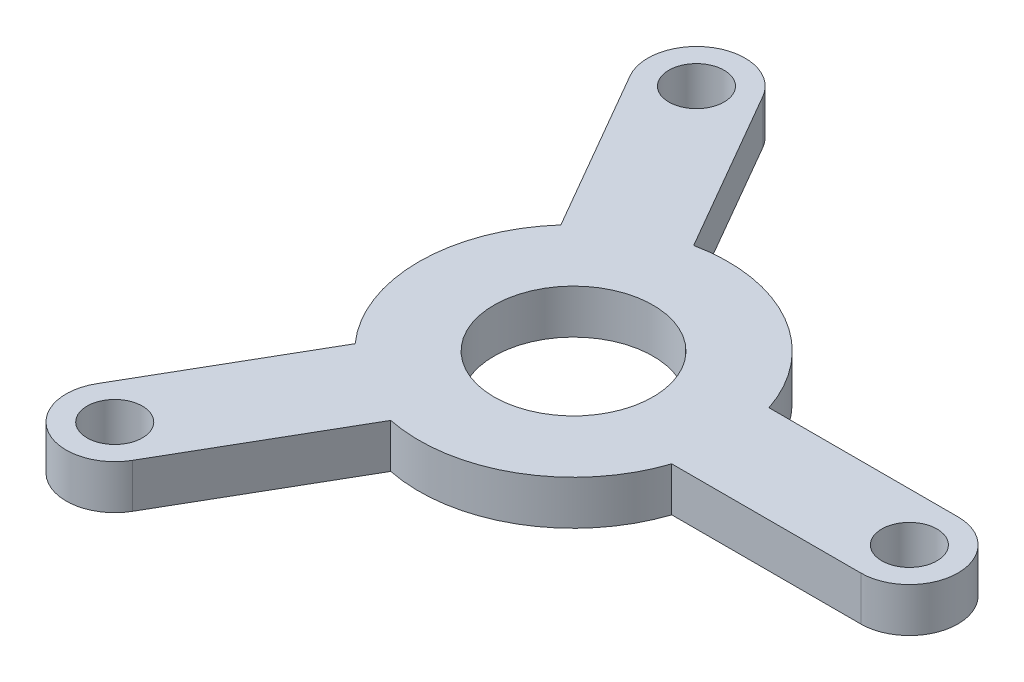
from build123d import *

# Parameters (mm, degrees)
SKETCH1_R           = 17.5
SKETCH1_R_2         = 9
BOSS_EXTRUDE1_DEPTH = 5
BOSS_EXTRUDE3_DEPTH = 5
CUT_EXTRUDE1_START  = -6
SKETCH4_R           = 3.125
CUT_EXTRUDE1_DEPTH  = 7
CIRPATTERN1_COUNT   = 3


with BuildPart() as part:
    # Sketch1 → Boss-Extrude1 (new body)
    with BuildSketch(Plane(origin=(0, 0, 0), x_dir=(1, 0, 0), z_dir=(0, 1, 0))):
        Circle(SKETCH1_R)
        Circle(SKETCH1_R_2, mode=Mode.SUBTRACT)
    extrude(amount=BOSS_EXTRUDE1_DEPTH)

    # Sketch3 → Boss-Extrude3 (add)
    with BuildSketch(Plane(origin=(0, 0, 0), x_dir=(1, 0, 0), z_dir=(0, 1, 0))):
        with BuildLine():
            Line((38, 5.5), (10.009906254, 5.5))
            Line((10.009906254, 5.5), (10.009906254, -5.5))
            Line((10.009906254, -5.5), (38, -5.5))
            ThreePointArc((38, -5.5), (32.5, 0), (38, 5.5))
        make_face()
        with BuildLine():
            ThreePointArc((43.5, 0), (41.889087297, 3.889087297), (38, 5.5))
            Line((38, 5.5), (38, -5.5))
            ThreePointArc((38, -5.5), (41.889087297, -3.889087297), (43.5, 0))
        make_face()
        with BuildLine():
            Line((38, -5.5), (38, 5.5))
            ThreePointArc((38, 5.5), (32.5, 0), (38, -5.5))
        make_face()
    boss_extrude3 = extrude(amount=BOSS_EXTRUDE3_DEPTH)

    # Sketch4 → Cut-Extrude1 (cut)
    with BuildSketch(Plane(origin=(0, 5, 0), x_dir=(1, 0, 0), z_dir=(0, 1, 0)).offset(CUT_EXTRUDE1_START)):
        with Locations((38, 0)):
            Circle(SKETCH4_R)
    cut_extrude1 = extrude(amount=CUT_EXTRUDE1_DEPTH, mode=Mode.SUBTRACT)

    # CirPattern1: Boss-Extrude3, Cut-Extrude1 ×3 about axis
    cirpattern1_axis = Axis((0, 0, 0), (0, 1, 0))
    for i in range(1, CIRPATTERN1_COUNT):
        add(boss_extrude3.rotate(cirpattern1_axis, i * 360 / CIRPATTERN1_COUNT))
        add(cut_extrude1.rotate(cirpattern1_axis, i * 360 / CIRPATTERN1_COUNT), mode=Mode.SUBTRACT)


solid = part.part
